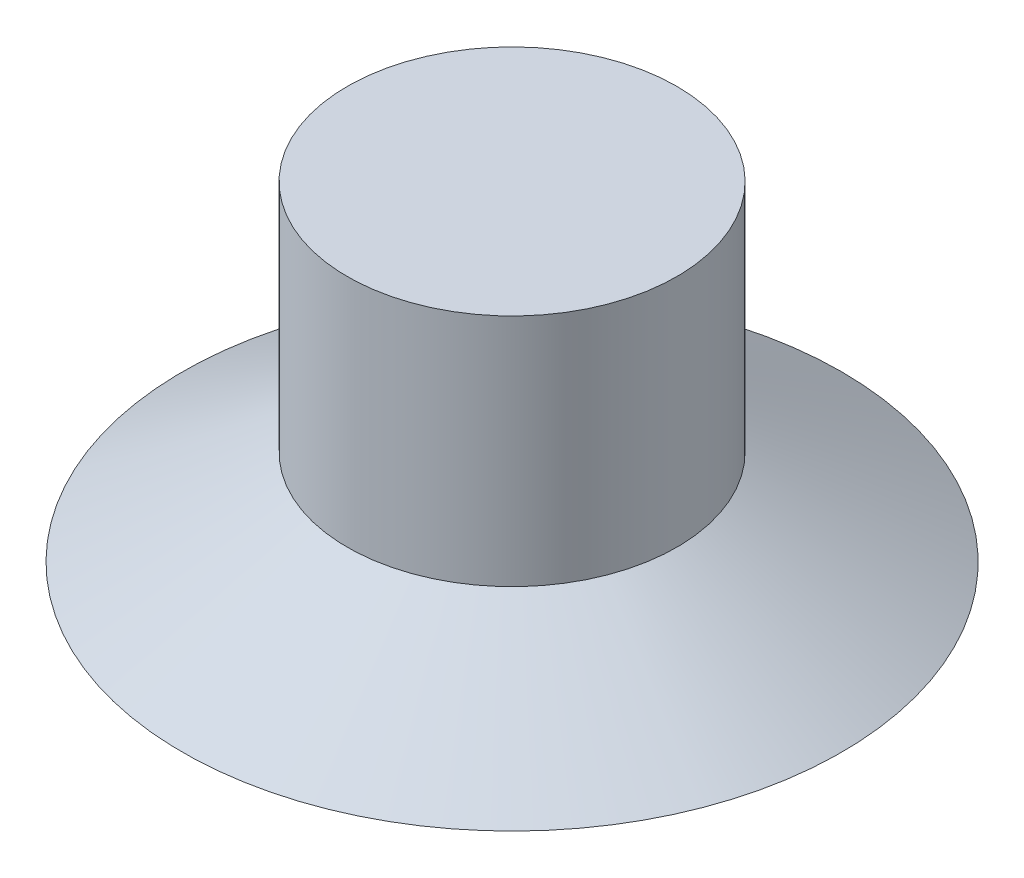
from build123d import *

# Parameters (mm, degrees)
ENL_V_MAT_EXTRU_1_DEPTH = 3


with BuildPart() as part:
    # Esquisse1 → Révolution1 (revolve)
    with BuildSketch(Plane.XY):
        Polygon((0, 0), (8, 0), (4, 2.309401077), (4, 8), (0, 8), align=None)
    revolve(axis=Axis((0, 0, 0), (0, 1, 0)))

    # Esquisse2 → Enlèv. mat.-Extru.1 (cut)
    with BuildSketch(Plane.XZ):
        Polygon((-3.464101615, 0), (-1.732050808, 3), (1.732050808, 3), (3.464101615, 0), (1.732050808, -3), (-1.732050808, -3), align=None)
    extrude(amount=-ENL_V_MAT_EXTRU_1_DEPTH, mode=Mode.SUBTRACT)


solid = part.part
